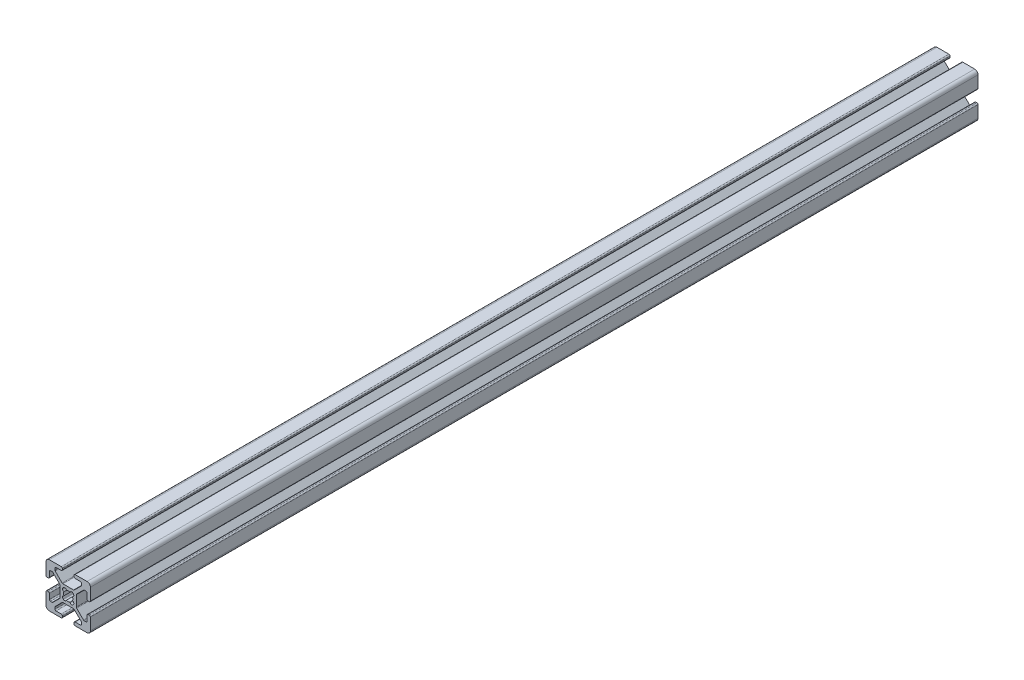
from build123d import *

# Parameters (mm, degrees)
EXTRUDE1_DEPTH = 400


with BuildPart() as part:
    # Sketch1 → Extrude1 (new body)
    with BuildSketch(Plane.XY):
        with BuildLine():
            Line((-5.032287798, -0.341059771), (-5.516287798, -0.341059771))
            ThreePointArc((-5.516287798, -0.341059771), (-5.875498042, -0.192270016), (-6.024287798, 0.166940229))
            Line((-6.024287798, 0.166940229), (-6.024287798, 2.515940229))
            ThreePointArc((-6.024287798, 2.515940229), (-6.173077553, 2.875150474), (-6.532287798, 3.023940229))
            Line((-6.532287798, 3.023940229), (-7.258207136, 3.023940229))
            ThreePointArc((-7.258207136, 3.023940229), (-7.45261032, 2.985271032), (-7.617417381, 2.875150474))
            Line((-7.617417381, 2.875150474), (-10.720498042, -0.227930187))
            ThreePointArc((-10.720498042, -0.227930187), (-10.8306186, -0.392737249), (-10.869287798, -0.587140432))
            Line((-10.869287798, -0.587140432), (-10.869287798, -5.354979109))
            ThreePointArc((-10.869287798, -5.354979109), (-10.8306186, -5.549382293), (-10.720498042, -5.714189354))
            Line((-10.720498042, -5.714189354), (-7.617417381, -8.817270016))
            ThreePointArc((-7.617417381, -8.817270016), (-7.45261032, -8.927390573), (-7.258207136, -8.966059771))
            Line((-7.258207136, -8.966059771), (-6.532287798, -8.966059771))
            ThreePointArc((-6.532287798, -8.966059771), (-6.173077553, -8.817270016), (-6.024287798, -8.458059771))
            Line((-6.024287798, -8.458059771), (-6.024287798, -6.109059771))
            ThreePointArc((-6.024287798, -6.109059771), (-5.875498042, -5.749849526), (-5.516287798, -5.601059771))
            Line((-5.516287798, -5.601059771), (-5.032287798, -5.601059771))
            ThreePointArc((-5.032287798, -5.601059771), (-4.673077553, -5.749849526), (-4.524287798, -6.109059771))
            Line((-4.524287798, -6.109059771), (-4.524287798, -11.471059771))
            ThreePointArc((-4.524287798, -11.471059771), (-4.963627626, -12.531719943), (-6.024287798, -12.971059771))
            Line((-6.024287798, -12.971059771), (-11.386287798, -12.971059771))
            ThreePointArc((-11.386287798, -12.971059771), (-11.745498042, -12.822270016), (-11.894287798, -12.463059771))
            Line((-11.894287798, -12.463059771), (-11.894287798, -11.979059771))
            ThreePointArc((-11.894287798, -11.979059771), (-11.745498042, -11.619849526), (-11.386287798, -11.471059771))
            Line((-11.386287798, -11.471059771), (-9.037287798, -11.471059771))
            ThreePointArc((-9.037287798, -11.471059771), (-8.678077553, -11.322270016), (-8.529287798, -10.963059771))
            Line((-8.529287798, -10.963059771), (-8.529287798, -10.237140432))
            ThreePointArc((-8.529287798, -10.237140432), (-8.567956995, -10.042737249), (-8.678077553, -9.877930187))
            Line((-8.678077553, -9.877930187), (-11.781158214, -6.774849526))
            ThreePointArc((-11.781158214, -6.774849526), (-11.945965275, -6.664728968), (-12.140368459, -6.626059771))
            Line((-12.140368459, -6.626059771), (-16.908207136, -6.626059771))
            ThreePointArc((-16.908207136, -6.626059771), (-17.10261032, -6.664728968), (-17.267417381, -6.774849526))
            Line((-17.267417381, -6.774849526), (-20.370498042, -9.877930187))
            ThreePointArc((-20.370498042, -9.877930187), (-20.4806186, -10.042737249), (-20.519287798, -10.237140432))
            Line((-20.519287798, -10.237140432), (-20.519287798, -10.963059771))
            ThreePointArc((-20.519287798, -10.963059771), (-20.370498042, -11.322270016), (-20.011287798, -11.471059771))
            Line((-20.011287798, -11.471059771), (-17.662287798, -11.471059771))
            ThreePointArc((-17.662287798, -11.471059771), (-17.303077553, -11.619849526), (-17.154287798, -11.979059771))
            Line((-17.154287798, -11.979059771), (-17.154287798, -12.463059771))
            ThreePointArc((-17.154287798, -12.463059771), (-17.303077553, -12.822270016), (-17.662287798, -12.971059771))
            Line((-17.662287798, -12.971059771), (-23.024287798, -12.971059771))
            ThreePointArc((-23.024287798, -12.971059771), (-24.084947969, -12.531719943), (-24.524287798, -11.471059771))
            Line((-24.524287798, -11.471059771), (-24.524287798, -6.109059771))
            ThreePointArc((-24.524287798, -6.109059771), (-24.375498042, -5.749849526), (-24.016287798, -5.601059771))
            Line((-24.016287798, -5.601059771), (-23.532287798, -5.601059771))
            ThreePointArc((-23.532287798, -5.601059771), (-23.173077553, -5.749849526), (-23.024287798, -6.109059771))
            Line((-23.024287798, -6.109059771), (-23.024287798, -8.458059771))
            ThreePointArc((-23.024287798, -8.458059771), (-22.875498042, -8.817270016), (-22.516287798, -8.966059771))
            Line((-22.516287798, -8.966059771), (-21.790368459, -8.966059771))
            ThreePointArc((-21.790368459, -8.966059771), (-21.595965275, -8.927390573), (-21.431158214, -8.817270016))
            Line((-21.431158214, -8.817270016), (-18.328077553, -5.714189354))
            ThreePointArc((-18.328077553, -5.714189354), (-18.217956995, -5.549382293), (-18.179287798, -5.354979109))
            Line((-18.179287798, -5.354979109), (-18.179287798, -0.587140432))
            ThreePointArc((-18.179287798, -0.587140432), (-18.217956995, -0.392737249), (-18.328077553, -0.227930187))
            Line((-18.328077553, -0.227930187), (-21.431158214, 2.875150474))
            ThreePointArc((-21.431158214, 2.875150474), (-21.595965275, 2.985271032), (-21.790368459, 3.023940229))
            Line((-21.790368459, 3.023940229), (-22.516287798, 3.023940229))
            ThreePointArc((-22.516287798, 3.023940229), (-22.875498042, 2.875150474), (-23.024287798, 2.515940229))
            Line((-23.024287798, 2.515940229), (-23.024287798, 0.166940229))
            ThreePointArc((-23.024287798, 0.166940229), (-23.173077553, -0.192270016), (-23.532287798, -0.341059771))
            Line((-23.532287798, -0.341059771), (-24.016287798, -0.341059771))
            ThreePointArc((-24.016287798, -0.341059771), (-24.375498042, -0.192270016), (-24.524287798, 0.166940229))
            Line((-24.524287798, 0.166940229), (-24.524287798, 5.528940229))
            ThreePointArc((-24.524287798, 5.528940229), (-24.084947969, 6.589600401), (-23.024287798, 7.028940229))
            Line((-23.024287798, 7.028940229), (-17.662287798, 7.028940229))
            ThreePointArc((-17.662287798, 7.028940229), (-17.303077553, 6.880150474), (-17.154287798, 6.520940229))
            Line((-17.154287798, 6.520940229), (-17.154287798, 6.036940229))
            ThreePointArc((-17.154287798, 6.036940229), (-17.303077553, 5.677729984), (-17.662287798, 5.528940229))
            Line((-17.662287798, 5.528940229), (-20.011287798, 5.528940229))
            ThreePointArc((-20.011287798, 5.528940229), (-20.370498042, 5.380150474), (-20.519287798, 5.020940229))
            Line((-20.519287798, 5.020940229), (-20.519287798, 4.295020891))
            ThreePointArc((-20.519287798, 4.295020891), (-20.4806186, 4.100617707), (-20.370498042, 3.935810646))
            Line((-20.370498042, 3.935810646), (-17.267417381, 0.832729984))
            ThreePointArc((-17.267417381, 0.832729984), (-17.10261032, 0.722609427), (-16.908207136, 0.683940229))
            Line((-16.908207136, 0.683940229), (-12.140368459, 0.683940229))
            ThreePointArc((-12.140368459, 0.683940229), (-11.945965275, 0.722609427), (-11.781158214, 0.832729984))
            Line((-11.781158214, 0.832729984), (-8.678077553, 3.935810646))
            ThreePointArc((-8.678077553, 3.935810646), (-8.567956995, 4.100617707), (-8.529287798, 4.295020891))
            Line((-8.529287798, 4.295020891), (-8.529287798, 5.020940229))
            ThreePointArc((-8.529287798, 5.020940229), (-8.678077553, 5.380150474), (-9.037287798, 5.528940229))
            Line((-9.037287798, 5.528940229), (-11.386287798, 5.528940229))
            ThreePointArc((-11.386287798, 5.528940229), (-11.745498042, 5.677729984), (-11.894287798, 6.036940229))
            Line((-11.894287798, 6.036940229), (-11.894287798, 6.520940229))
            ThreePointArc((-11.894287798, 6.520940229), (-11.745498042, 6.880150474), (-11.386287798, 7.028940229))
            Line((-11.386287798, 7.028940229), (-6.024287798, 7.028940229))
            ThreePointArc((-6.024287798, 7.028940229), (-4.963627626, 6.589600401), (-4.524287798, 5.528940229))
            Line((-4.524287798, 5.528940229), (-4.524287798, 0.166940229))
            ThreePointArc((-4.524287798, 0.166940229), (-4.673077553, -0.192270016), (-5.032287798, -0.341059771))
        make_face()
        with BuildLine():
            Line((-12.399386954, -5.275565737), (-12.219781831, -5.095960615))
            ThreePointArc((-12.219781831, -5.095960615), (-12.018349781, -4.327527582), (-12.589154291, -3.775036489))
            ThreePointArc((-12.589154291, -3.775036489), (-12.428787798, -2.971059771), (-12.589154291, -2.167083053))
            ThreePointArc((-12.589154291, -2.167083053), (-12.018349781, -1.61459196), (-12.219781831, -0.846158927))
            Line((-12.219781831, -0.846158927), (-12.399386954, -0.666553805))
            ThreePointArc((-12.399386954, -0.666553805), (-13.167819987, -0.465121754), (-13.72031108, -1.035926265))
            ThreePointArc((-13.72031108, -1.035926265), (-14.524287798, -0.875559771), (-15.328264516, -1.035926265))
            ThreePointArc((-15.328264516, -1.035926265), (-15.880755608, -0.465121754), (-16.649188641, -0.666553805))
            Line((-16.649188641, -0.666553805), (-16.828793764, -0.846158927))
            ThreePointArc((-16.828793764, -0.846158927), (-17.030225814, -1.61459196), (-16.459421304, -2.167083053))
            ThreePointArc((-16.459421304, -2.167083053), (-16.619787798, -2.971059771), (-16.459421304, -3.775036489))
            ThreePointArc((-16.459421304, -3.775036489), (-17.030225814, -4.327527582), (-16.828793764, -5.095960615))
            Line((-16.828793764, -5.095960615), (-16.649188641, -5.275565737))
            ThreePointArc((-16.649188641, -5.275565737), (-15.880755608, -5.476997788), (-15.328264516, -4.906193277))
            ThreePointArc((-15.328264516, -4.906193277), (-14.524287798, -5.066559771), (-13.72031108, -4.906193277))
            ThreePointArc((-13.72031108, -4.906193277), (-13.167819987, -5.476997788), (-12.399386954, -5.275565737))
        make_face(mode=Mode.SUBTRACT)
    extrude(amount=EXTRUDE1_DEPTH)


solid = part.part
